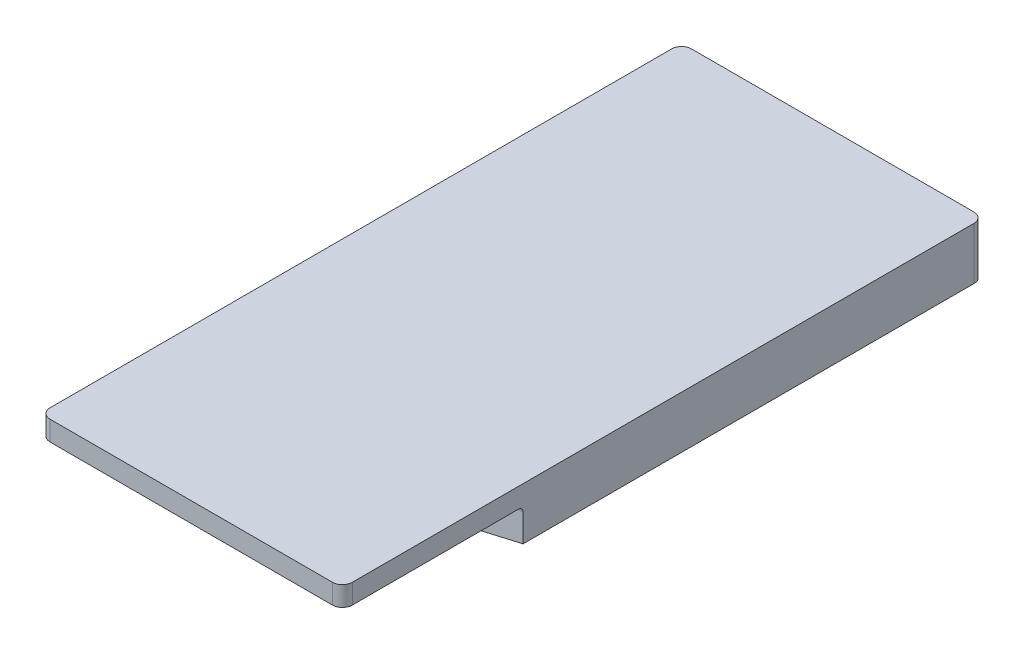
from build123d import *

# Parameters (mm, degrees)
BOSS_EXTRUDE1_DEPTH = 591.5
SKETCH2_W           = 388.02090207
SKETCH2_H           = 25.404192512
BOSS_EXTRUDE2_DEPTH = 232
FILLET1_R           = 12.7
FILLET3_R           = 6.35


with BuildPart() as part:
    # Sketch1 → Boss-Extrude1 (new body)
    with BuildSketch(Plane(origin=(0, 0, -411.75), x_dir=(-1, 0, 0), z_dir=(0, 0, -1))):
        with BuildLine():
            Line((121.01, 20.009665474), (194.010451035, 36.954192512))
            Line((194.010451035, 36.954192512), (194.010451035, 103.904192512))
            Line((194.010451035, 103.904192512), (-194.010451035, 103.904192512))
            Line((-194.010451035, 103.904192512), (-194.010451035, 36.954192512))
            Line((-194.010451035, 36.954192512), (-121.01, 20.009665474))
            Line((-121.01, 20.009665474), (-121.01, 39))
            ThreePointArc((-121.01, 39), (-88.51, 71.5), (-56.01, 39))
            Line((-56.01, 39), (-56.01, 5.206473282))
            ThreePointArc((-56.01, 5.206473282), (0, 0), (56.01, 5.206473282))
            Line((56.01, 5.206473282), (56.01, 39))
            ThreePointArc((56.01, 39), (88.51, 71.5), (121.01, 39))
            Line((121.01, 39), (121.01, 20.009665474))
        make_face()
    extrude(amount=-BOSS_EXTRUDE1_DEPTH)

    # Sketch2 → Boss-Extrude2 (add)
    with BuildSketch(Plane.XY.offset(179.75)):
        with Locations((0, 91.202096256)):
            Rectangle(SKETCH2_W, SKETCH2_H)
    extrude(amount=BOSS_EXTRUDE2_DEPTH)

    # Fillet1
    fillet1_edges = [part.edges().sort_by_distance(p)[0] for p in [
        (194.010451035, 70.429192512, -411.75),
        (-194.010451035, 70.429192512, -411.75),
        (194.010451035, 91.202096256, 411.75),
        (-194.010451035, 91.202096256, 411.75),
    ]]
    fillet(fillet1_edges, radius=FILLET1_R)

    # Fillet3
    fillet3_edges = [part.edges().sort_by_distance(p)[0] for p in [
        (0, 78.5, 179.75),
    ]]
    fillet(fillet3_edges, radius=FILLET3_R)


solid = part.part
